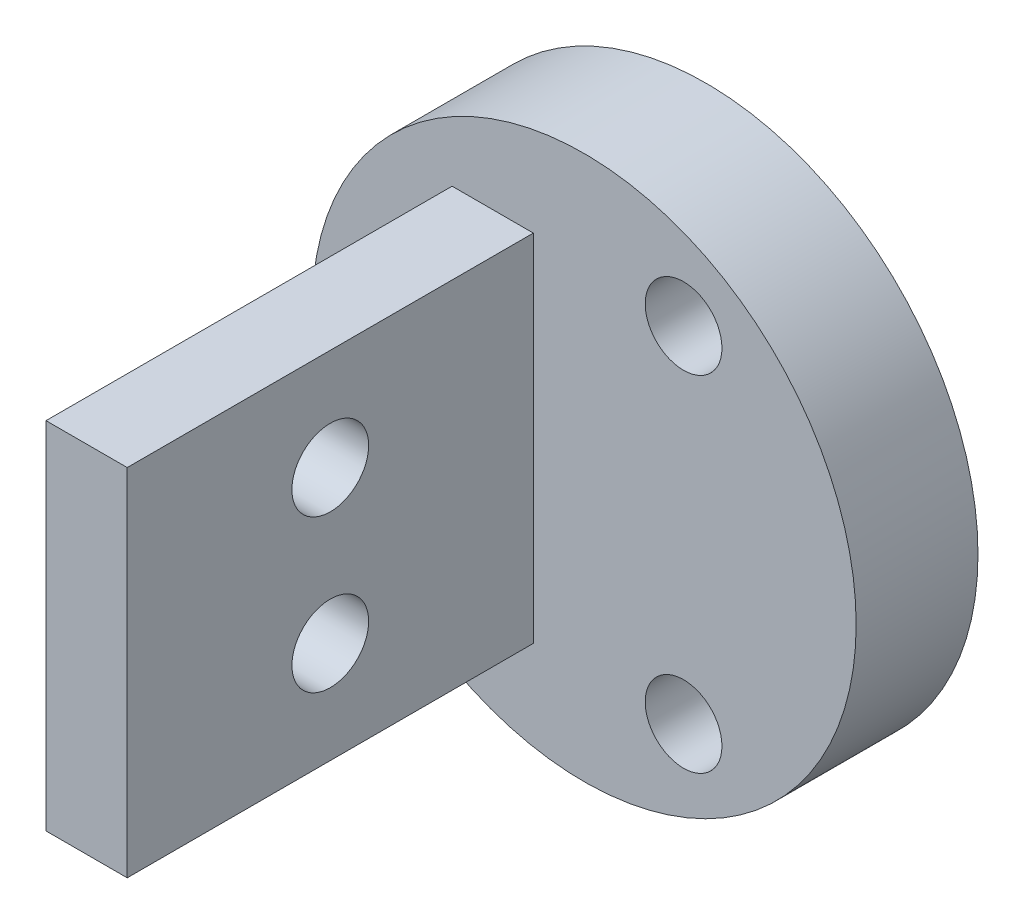
from build123d import *

# Parameters (mm, degrees)
SKETCH2_R            = 8.509
BOSS_EXTRUDE1_DEPTH  = 3.81
SKETCH4_W            = 2.54
SKETCH4_H            = 11.1125
BOSS_EXTRUDE2_DEPTH  = 12.7
M2_CLEARANCE_HOLE1_D = 2.4
M2_CLEARANCE_HOLE2_D = 2.4


with BuildPart() as part:
    # Sketch2 → Boss-Extrude1 (new body)
    with BuildSketch(Plane.XY):
        Circle(SKETCH2_R)
    extrude(amount=BOSS_EXTRUDE1_DEPTH)

    # Sketch4 → Boss-Extrude2 (add)
    with BuildSketch(Plane.XY.offset(3.81)):
        with Locations((-2.8575, 0)):
            Rectangle(SKETCH4_W, SKETCH4_H)
    extrude(amount=BOSS_EXTRUDE2_DEPTH)

    # M2 Clearance Hole1 (through all)
    with Locations(Plane.XY.offset(3.81)):
        with Locations((-6.223, 0), (3.1115, 5.389276088), (3.1115, -5.389276088)):
            Hole(M2_CLEARANCE_HOLE1_D / 2)

    # M2 Clearance Hole2 (through all)
    with Locations(Plane(origin=(-1.5875, 0, 0), x_dir=(0, 0, -1), z_dir=(1, 0, 0))):
        with Locations((-10.16, -2.38125), (-10.16, 2.38125)):
            Hole(M2_CLEARANCE_HOLE2_D / 2)


solid = part.part
